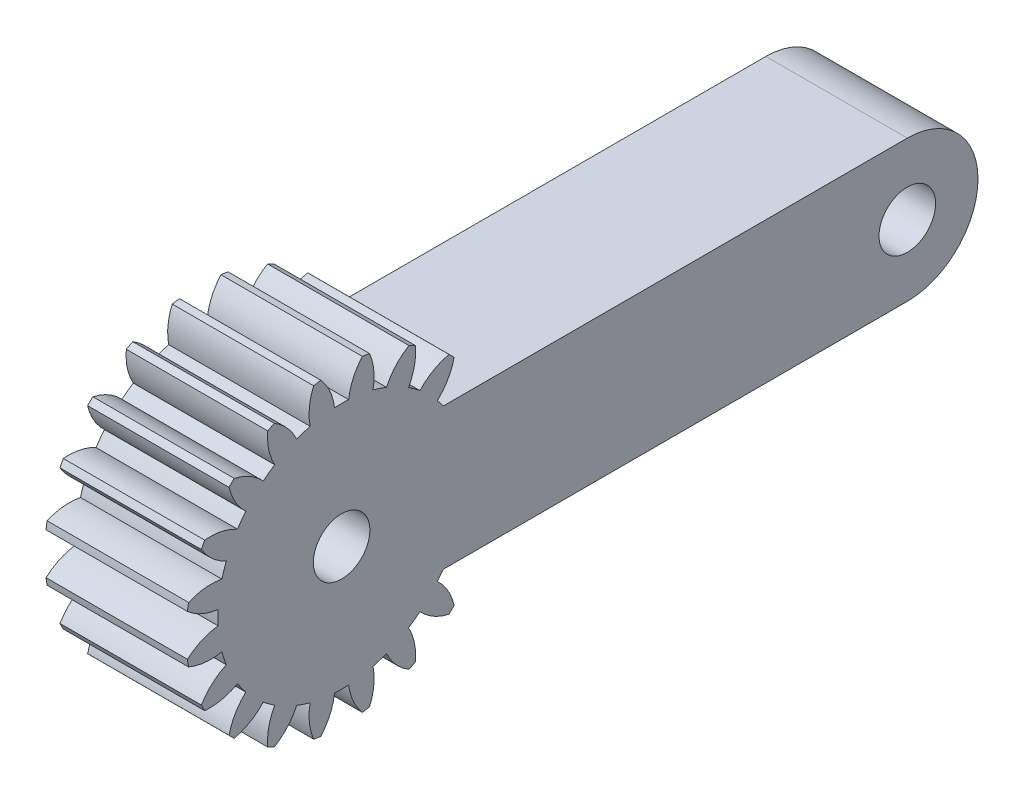
from build123d import *

# Parameters (mm, degrees)
BASPROSKE_W             = 10
BASPROSKE_H             = 11
TOOTHCUT_DEPTH          = 19.493242009
TEETHCUTS_COUNT         = 20
TEETHCUTS_ANGLE         = 342
BORSKE_R                = 0.4
BORE_DEPTH              = 50.0000508
CROQUIS1_R              = 2
SALIENTE_EXTRUIR1_DEPTH = 10
CROQUIS2_R              = 2
CORTAR_EXTRUIR1_DEPTH   = 10
CORTAR_EXTRUIR2_DEPTH   = 10


with BuildPart() as part:
    # BasProSke → Base-Revolve (revolve)
    with BuildSketch(Plane(origin=(0, 0, 0), x_dir=(1, 0, 0), z_dir=(0, 1, 0)), mode=Mode.PRIVATE) as base_revolve_sk:
        with Locations((5, 5.5)):
            Rectangle(BASPROSKE_W, BASPROSKE_H)
    revolve(base_revolve_sk.sketch.rotate(Axis((-10, 0, 0), (1, 0, 0)), 180), axis=Axis((-10, 0, 0), (1, 0, 0)))

    # TooCutSke → ToothCut (cut, through all)
    with BuildSketch(Plane(origin=(0, 0, 0), x_dir=(0, 0, -1), z_dir=(1, 0, 0))):
        with BuildLine():
            ThreePointArc((0.499924007, 8.734705318), (0, 8.749), (-0.499924007, 8.734705318))
            ThreePointArc((-0.499924007, 8.734705318), (-0.824302243, 9.905497836), (-1.485192705, 10.924909509))
            ThreePointArc((-1.485192705, 10.924909509), (0, 11.0254), (1.485192705, 10.924909509))
            ThreePointArc((1.485192705, 10.924909509), (0.824302243, 9.905497836), (0.499924007, 8.734705318))
        make_face()
    toothcut = extrude(amount=TOOTHCUT_DEPTH, mode=Mode.SUBTRACT)

    # TeethCuts: ToothCut ×20 about axis
    teethcuts_axis = Axis((-10, 0, 0), (1, 0, 0))
    for i in range(1, TEETHCUTS_COUNT):
        add(toothcut.rotate(teethcuts_axis, i * TEETHCUTS_ANGLE / (TEETHCUTS_COUNT - 1)), mode=Mode.SUBTRACT)

    # BorSke → Bore (cut, symmetric)
    with BuildSketch(Plane(origin=(0, 0, 0), x_dir=(0, 0, -1), z_dir=(1, 0, 0))):
        with Locations(Location((0, 0, 0), (0, 0, 180))):
            Circle(BORSKE_R)
    extrude(amount=BORE_DEPTH, both=True, mode=Mode.SUBTRACT)

    # Croquis1 → Saliente-Extruir1 (add)
    with BuildSketch(Plane(origin=(10, 0, 0), x_dir=(0, 0, -1), z_dir=(1, 0, 0))):
        with BuildLine():
            Line((40, 5), (0, 5))
            ThreePointArc((0, 5), (-5, 0), (0, -5))
            Line((0, -5), (40, -5))
            ThreePointArc((40, -5), (45, 0), (40, 5))
        make_face()
        Circle(CROQUIS1_R, mode=Mode.SUBTRACT)
        with Locations((40, 0)):
            Circle(CROQUIS1_R, mode=Mode.SUBTRACT)
    extrude(amount=-SALIENTE_EXTRUIR1_DEPTH)

    # Croquis2 → Cortar-Extruir1 (cut)
    with BuildSketch(Plane(origin=(10, 0, 0), x_dir=(0, 0, -1), z_dir=(1, 0, 0))):
        Circle(CROQUIS2_R)
    extrude(amount=-CORTAR_EXTRUIR1_DEPTH, mode=Mode.SUBTRACT)

    # Croquis3 → Cortar-Extruir2 (cut)
    with BuildSketch(Plane(origin=(10, 0, 0), x_dir=(0, 0, -1), z_dir=(1, 0, 0))):
        with BuildLine():
            Line((6.772677084, 5.538577987), (8.515195785, 6.963579593))
            ThreePointArc((8.515195785, 6.963579593), (9.209061868, 6.016076754), (9.797958971, 5))
            Line((9.797958971, 5), (7.179484731, 5))
            ThreePointArc((7.179484731, 5), (6.981276487, 5.273213405), (6.772677084, 5.538577987))
        make_face()
        with BuildLine():
            Line((6.772677084, -5.538577987), (8.515195785, -6.963579593))
            ThreePointArc((8.515195785, -6.963579593), (9.209061868, -6.016076754), (9.797958971, -5))
            Line((9.797958971, -5), (7.179484731, -5))
            ThreePointArc((7.179484731, -5), (6.981276487, -5.273213405), (6.772677084, -5.538577987))
        make_face()
    extrude(amount=-CORTAR_EXTRUIR2_DEPTH, mode=Mode.SUBTRACT)


solid = part.part
